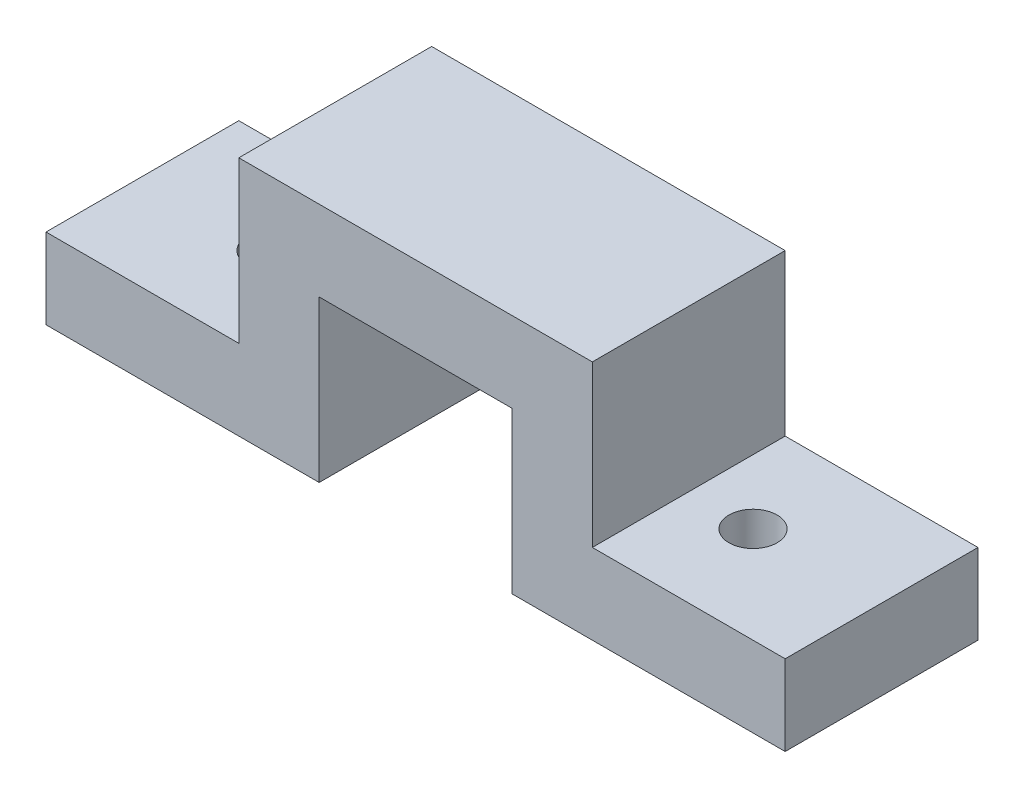
from build123d import *

# Parameters (mm, degrees)
EXTRUDE_1_DEPTH         = 12
SKETCH_2_R              = 1.5
CUT_EXTRUDE3_DEPTH      = 16
CUT_EXTRUDE3_DEPTH_BACK = 10


with BuildPart() as part:
    # 草图1 → 凸台-拉伸1 (new body)
    with BuildSketch(Plane.XY):
        Polygon((-11, 15), (11, 15), (11, 5), (23, 5), (23, 0), (6, 0), (6, 10), (-6, 10), (-6, 0), (-23, 0), (-23, 5), (-11, 5), align=None)
    extrude(amount=EXTRUDE_1_DEPTH)

    # 草图2 → Cut-Extrude3 (cut, two sides)
    with BuildSketch(Plane(origin=(0, 0, 0), x_dir=(1, 0, 0), z_dir=(0, 1, 0))) as cut_extrude3_sk:
        with Locations((-15, -6)):
            Circle(SKETCH_2_R)
        with Locations((15, -6)):
            Circle(SKETCH_2_R)
    extrude(amount=CUT_EXTRUDE3_DEPTH, mode=Mode.SUBTRACT)
    extrude(cut_extrude3_sk.sketch, amount=-CUT_EXTRUDE3_DEPTH_BACK, mode=Mode.SUBTRACT)


solid = part.part
